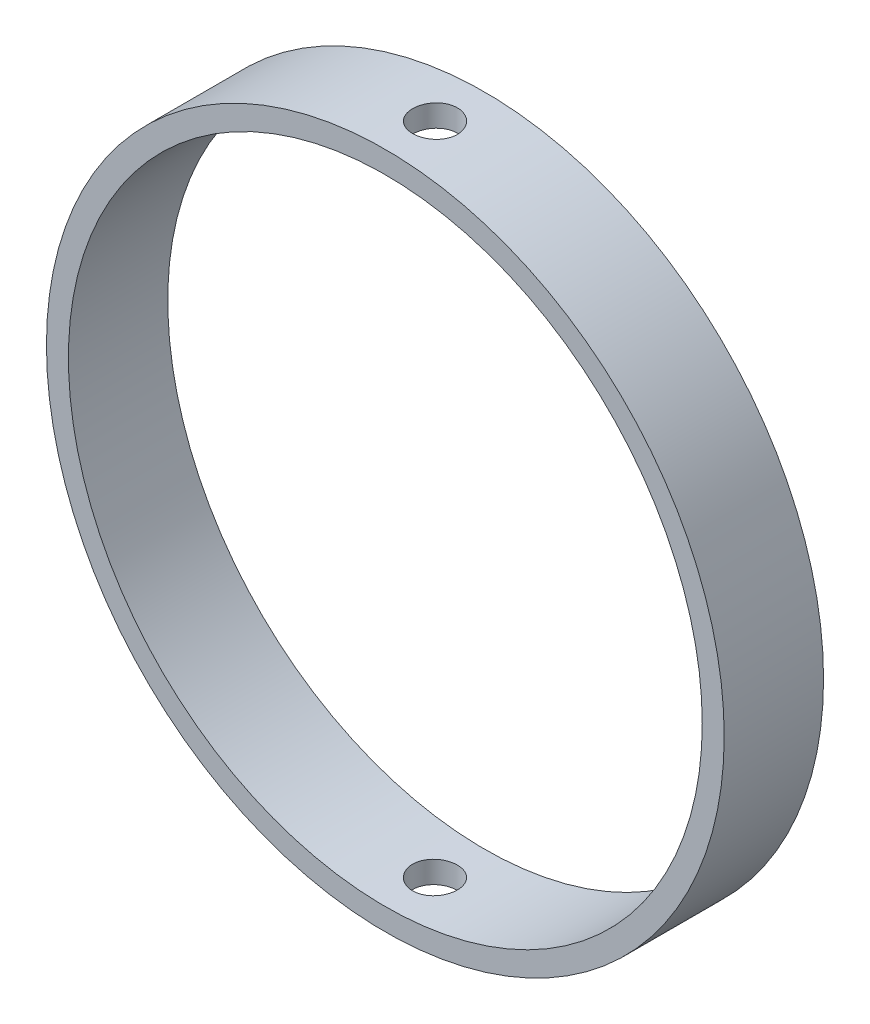
from build123d import *

# Parameters (mm, degrees)
SKETCH1_R           = 34.11
SKETCH1_R_2         = 31.9
BOSS_EXTRUDE1_DEPTH = 10
SKETCH2_R           = 2.25
CUT_EXTRUDE1_DEPTH  = 69.22


with BuildPart() as part:
    # Sketch1 → Boss-Extrude1 (new body)
    with BuildSketch(Plane.XY):
        Circle(SKETCH1_R)
        Circle(SKETCH1_R_2, mode=Mode.SUBTRACT)
    extrude(amount=BOSS_EXTRUDE1_DEPTH)

    # Sketch2 → Cut-Extrude1 (cut, through all)
    with BuildSketch(Plane(origin=(0, 34.11, 0), x_dir=(1, 0, 0), z_dir=(0, 1, 0))):
        with Locations((0, -5)):
            Circle(SKETCH2_R)
    extrude(amount=-CUT_EXTRUDE1_DEPTH, mode=Mode.SUBTRACT)


solid = part.part
